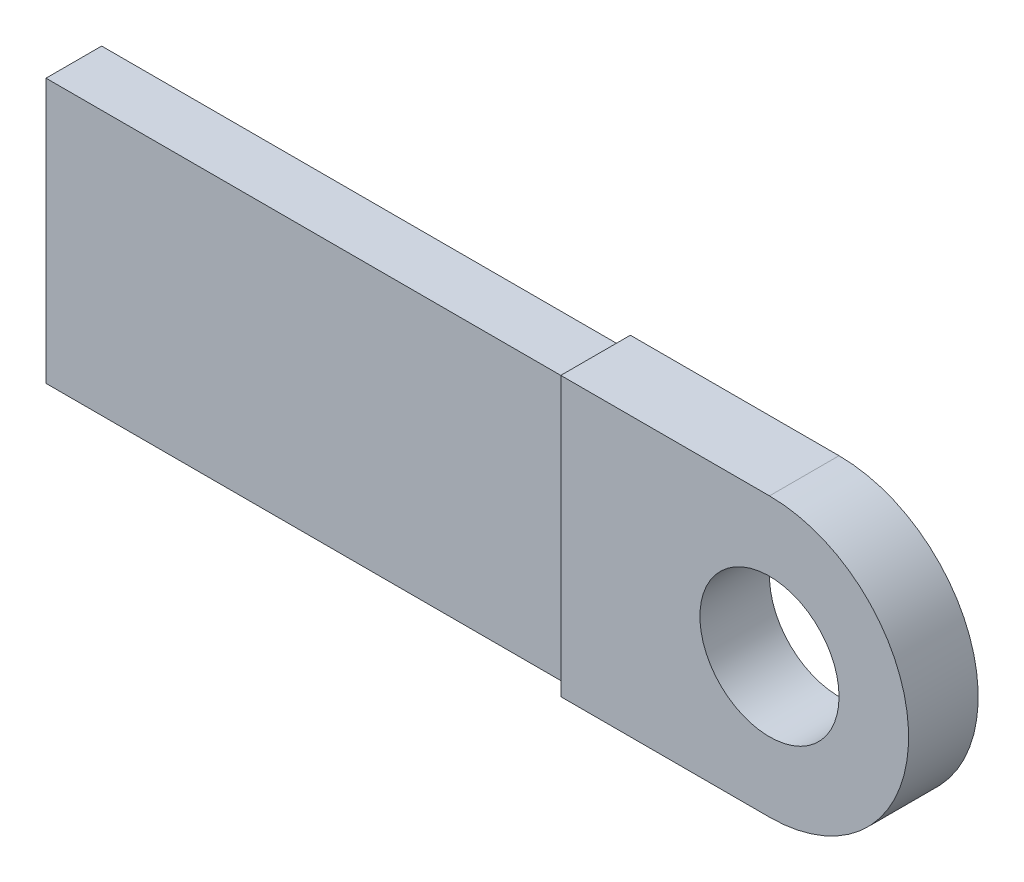
from build123d import *

# Parameters (mm, degrees)
BOSS_EXTRUDE1_DEPTH = 20
SKETCH2_R           = 20
CUT_EXTRUDE1_DEPTH  = 21
SKETCH3_W           = 16
SKETCH3_H           = 76
BOSS_EXTRUDE2_DEPTH = 150


with BuildPart() as part:
    # Sketch1 → Boss-Extrude1 (new body)
    with BuildSketch(Plane.XY):
        with BuildLine():
            Line((0, 80), (0, 0))
            Line((0, 0), (60, 0))
            ThreePointArc((60, 0), (88.284271247, 11.715728753), (100, 40))
            ThreePointArc((100, 40), (88.284271247, 68.284271247), (60, 80))
            Line((60, 80), (0, 80))
        make_face()
    extrude(amount=BOSS_EXTRUDE1_DEPTH)

    # Sketch2 → Cut-Extrude1 (cut, through all)
    with BuildSketch(Plane.XY.offset(20)):
        with Locations((60, 40)):
            Circle(SKETCH2_R)
    extrude(amount=-CUT_EXTRUDE1_DEPTH, mode=Mode.SUBTRACT)

    # Sketch3 → Boss-Extrude2 (add)
    with BuildSketch(Plane.ZY):
        with Locations((10, 40)):
            Rectangle(SKETCH3_W, SKETCH3_H)
    extrude(amount=BOSS_EXTRUDE2_DEPTH)


solid = part.part
